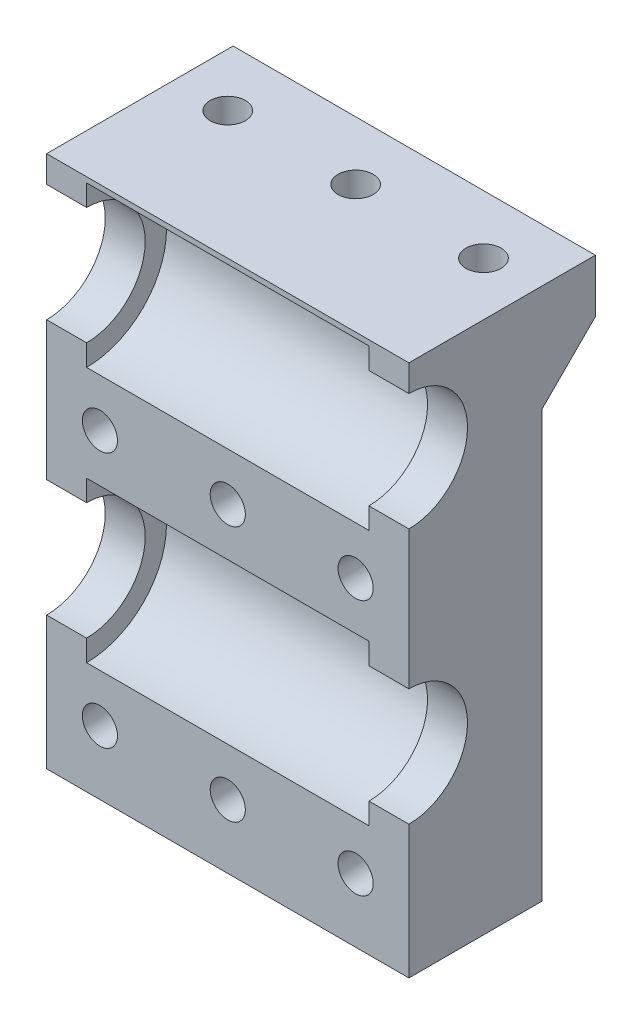
from build123d import *

# Parameters (mm, degrees)
SKETCH_1_W             = 12.5
SKETCH_1_H             = 50
EXTRUDE_1_DEPTH        = 34
SKETCH_2_R             = 7.5
CUT_EXTRUDE_1_DEPTH    = 13.25
CUT_EXTRUDE_START      = -13.5
SKETCH_3_R             = 1.65
CUT_EXTRUDE_2_DEPTH    = 14.5
SKETCH_4_R             = 2.9
CUT_EXTRUDE_3_DEPTH    = 4.5
SKETCH_5_R             = 5.5
CUT_EXTRUDE_4_DEPTH    = 35
EXTRUDE_2_DEPTH        = 17
SKETCH_9_R             = 1.65
CUT_EXTRUDE_6_DEPTH    = 6
CUT_EXTRUDE_5_DEPTH    = 9
PATTERN_LINEAR_1_COUNT = 2
PATTERN_LINEAR_1_PITCH = 24


with BuildPart() as part:
    # 草图1 → 凸台-拉伸1 (new body)
    with BuildSketch(Plane(origin=(0, 0, 0), x_dir=(0, 0, -1), z_dir=(1, 0, 0))):
        with Locations((6.25, 25)):
            Rectangle(SKETCH_1_W, SKETCH_1_H)
    extrude(amount=EXTRUDE_1_DEPTH)

    # 草图2 → 切除-拉伸1 (cut, symmetric)
    with BuildSketch(Plane.ZY.offset(-17)):
        with Locations((0, 18)):
            Circle(SKETCH_2_R)
        with Locations((0, 42)):
            Circle(SKETCH_2_R)
    extrude(amount=CUT_EXTRUDE_1_DEPTH, both=True, mode=Mode.SUBTRACT)

    # 草图3 → 切除-拉伸2 (cut)
    with BuildSketch(Plane(origin=(0, 0, -12.5), x_dir=(-1, 0, 0), z_dir=(0, 0, -1)).offset(CUT_EXTRUDE_START)):
        with Locations((-29, 30)):
            Circle(SKETCH_3_R)
        with Locations((-5, 30)):
            Circle(SKETCH_3_R)
        with Locations((-17, 30)):
            Circle(SKETCH_3_R)
    cut_extrude_2 = extrude(amount=CUT_EXTRUDE_2_DEPTH, mode=Mode.SUBTRACT)

    # 草图4 → 切除-拉伸3 (cut)
    with BuildSketch(Plane(origin=(0, 0, -12.5), x_dir=(-1, 0, 0), z_dir=(0, 0, -1))):
        with Locations((-29, 30)):
            Circle(SKETCH_4_R)
        with Locations((-5, 30)):
            Circle(SKETCH_4_R)
    extrude(amount=-CUT_EXTRUDE_3_DEPTH, mode=Mode.SUBTRACT)

    # 草图5 → 切除-拉伸4 (cut, through all)
    with BuildSketch(Plane(origin=(34, 0, 0), x_dir=(0, 0, -1), z_dir=(1, 0, 0))):
        with Locations((0, 18)):
            Circle(SKETCH_5_R)
        with Locations((0, 42)):
            Circle(SKETCH_5_R)
    extrude(amount=-CUT_EXTRUDE_4_DEPTH, mode=Mode.SUBTRACT)

    # 草图6 → 凸台-拉伸2 (add, symmetric)
    with BuildSketch(Plane.ZY.offset(-17)):
        Polygon((-12.5, 50), (-17.5, 50), (-17.5, 45), (-12.5, 40), align=None)
    extrude(amount=EXTRUDE_2_DEPTH, both=True)

    # 草图9 → 切除-拉伸6 (cut, through all)
    with BuildSketch(Plane(origin=(0, 45, 0), x_dir=(1, 0, 0), z_dir=(0, 1, 0))):
        with Locations((5, 12)):
            Circle(SKETCH_9_R)
        with Locations((17, 12)):
            Circle(SKETCH_9_R)
        with Locations((29, 12)):
            Circle(SKETCH_9_R)
    extrude(amount=CUT_EXTRUDE_6_DEPTH, mode=Mode.SUBTRACT)

    # 草图7 → 切除-拉伸5 (cut)
    with BuildSketch(Plane(origin=(0, 45, 0), x_dir=(1, 0, 0), z_dir=(0, 1, 0))):
        Polygon((7.85, 10.354551733), (7.85, 13.090838694), (7.85, 17.5), (2.15, 17.5), (2.15, 12.981963635), (2.15, 10.354551733), (5, 8.709103466), align=None)
        Polygon((19.85, 10.354551733), (19.85, 13.090959175), (19.85, 17.5), (14.15, 17.5), (14.15, 12.981963635), (14.15, 10.354551733), (17, 8.709103466), align=None)
        Polygon((31.85, 10.354551733), (31.85, 13.090958614), (31.85, 17.5), (26.15, 17.5), (26.15, 12.981963635), (26.15, 10.354551733), (29, 8.709103466), align=None)
    extrude(amount=-CUT_EXTRUDE_5_DEPTH, mode=Mode.SUBTRACT)

    # 阵列(线性)1: 切除-拉伸2 ×2
    with Locations(*[(0, -i * PATTERN_LINEAR_1_PITCH, 0) for i in range(1, PATTERN_LINEAR_1_COUNT)]):
        add(cut_extrude_2, mode=Mode.SUBTRACT)


solid = part.part
